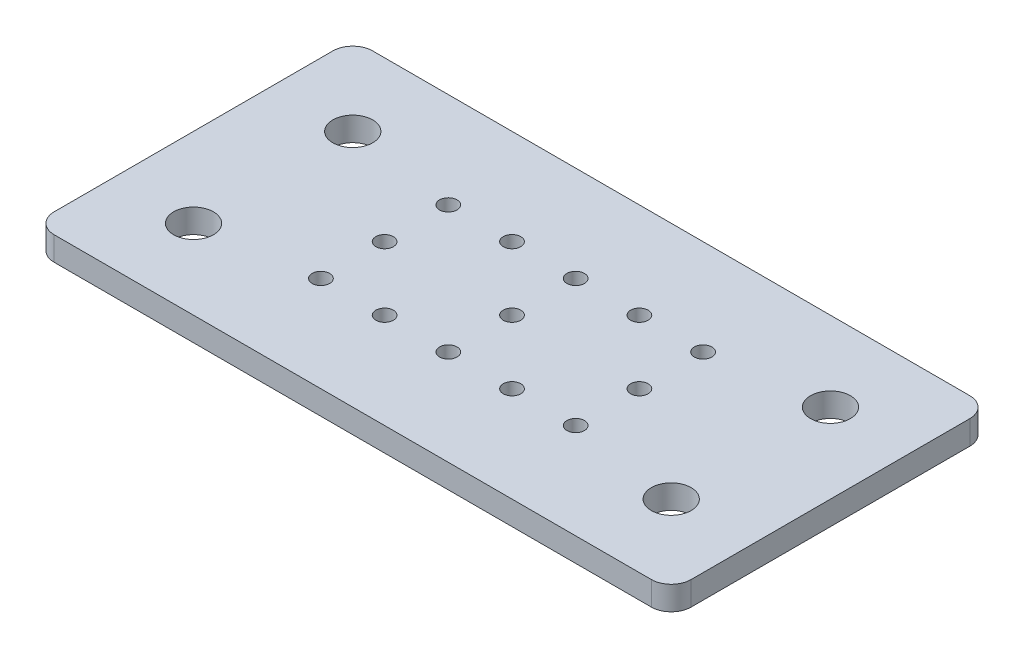
from build123d import *

# Parameters (mm, degrees)
ESQUISSE1_W      = 80
ESQUISSE1_H      = 40
ESQUISSE1_R      = 2.5
ESQUISSE1_R_2    = 1.1
EXTRUSION1_DEPTH = 3
CONG_1_R         = 2.5


with BuildPart() as part:
    # Esquisse1 → Extrusion1 (new body)
    with BuildSketch(Plane(origin=(0, 0, 0), x_dir=(1, 0, 0), z_dir=(0, 1, 0))):
        with Locations((40, 20)):
            Rectangle(ESQUISSE1_W, ESQUISSE1_H)
        with Locations((10, 10)):
            Circle(ESQUISSE1_R, mode=Mode.SUBTRACT)
        with Locations((70, 10)):
            Circle(ESQUISSE1_R, mode=Mode.SUBTRACT)
        with Locations((70, 30)):
            Circle(ESQUISSE1_R, mode=Mode.SUBTRACT)
        with Locations((10, 30)):
            Circle(ESQUISSE1_R, mode=Mode.SUBTRACT)
        with Locations((40, 28)):
            Circle(ESQUISSE1_R_2, mode=Mode.SUBTRACT)
        with Locations((48, 28)):
            Circle(ESQUISSE1_R_2, mode=Mode.SUBTRACT)
        with Locations((56, 28)):
            Circle(ESQUISSE1_R_2, mode=Mode.SUBTRACT)
        with Locations((40, 20)):
            Circle(ESQUISSE1_R_2, mode=Mode.SUBTRACT)
        with Locations((24, 12)):
            Circle(ESQUISSE1_R_2, mode=Mode.SUBTRACT)
        with Locations((56, 20)):
            Circle(ESQUISSE1_R_2, mode=Mode.SUBTRACT)
        with Locations((40, 12)):
            Circle(ESQUISSE1_R_2, mode=Mode.SUBTRACT)
        with Locations((48, 12)):
            Circle(ESQUISSE1_R_2, mode=Mode.SUBTRACT)
        with Locations((56, 12)):
            Circle(ESQUISSE1_R_2, mode=Mode.SUBTRACT)
        with Locations((32, 12)):
            Circle(ESQUISSE1_R_2, mode=Mode.SUBTRACT)
        with Locations((24, 20)):
            Circle(ESQUISSE1_R_2, mode=Mode.SUBTRACT)
        with Locations((24, 28)):
            Circle(ESQUISSE1_R_2, mode=Mode.SUBTRACT)
        with Locations((32, 28)):
            Circle(ESQUISSE1_R_2, mode=Mode.SUBTRACT)
    extrude(amount=EXTRUSION1_DEPTH)

    # Congé1
    cong_1_edges = [part.edges().sort_by_distance(p)[0] for p in [
        (0, 1.5, -40),
        (80, 1.5, -40),
        (80, 1.5, 0),
        (0, 1.5, 0),
    ]]
    fillet(cong_1_edges, radius=CONG_1_R)


solid = part.part
